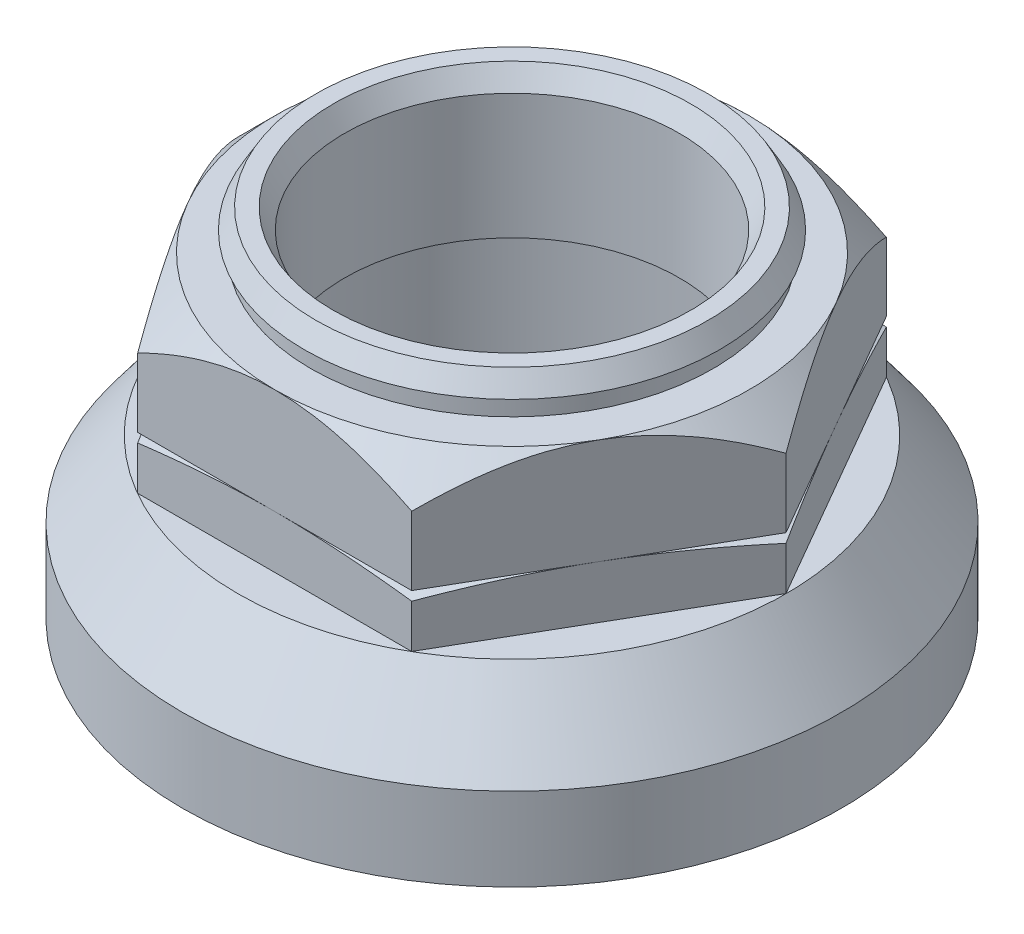
from build123d import *

# Parameters (mm, degrees)
SKETCH2_R      = 17
EXTRUDE1_DEPTH = 4
SKETCH5_R      = 12.7
EXTRUDE2_DEPTH = 8
SKETCH7_R      = 15.25
SKETCH7_R_2    = 12.7
EXTRUDE3_DEPTH = 1.5
SKETCH8_R      = 15.75
SKETCH8_R_2    = 12.7
EXTRUDE4_DEPTH = 1.5
EXTRUDE4_DRAFT = 30


with BuildPart() as part:
    # Sketch1 → Revolve1 (revolve)
    with BuildSketch(Plane(origin=(0, 0, 0), x_dir=(0, 0, -1), z_dir=(1, 0, 0))):
        Polygon((17, 2), (25, 2), (25, 8.3), (20.8, 14), (17, 14), align=None)
    revolve(axis=Axis((0, 2, 0), (0, 1, 0)))

    # Sketch2 → Extrude1 (add)
    with BuildSketch(Plane(origin=(0, 14, 0), x_dir=(1, 0, 0), z_dir=(0, 1, 0))):
        Polygon((10.392304845, 18), (-10.392304845, 18), (-20.784609691, 0), (-10.392304845, -18), (10.392304845, -18), (20.784609691, 0), align=None)
        with Locations(Location((0, 0, 0), (0, 0, 90))):  # turned: the seam where the file's is
            Circle(SKETCH2_R, mode=Mode.SUBTRACT)
    extrude(amount=EXTRUDE1_DEPTH)

    # SurfaceCut1: cut with a surface, the side it looks to stays
    # Surface-Revolve1: a surface, the sketch's curves turned about an axis
    with BuildLine(Plane(origin=(0, 0, 0), x_dir=(0, 0, -1), z_dir=(1, 0, 0)), mode=Mode.PRIVATE) as surface_revolve1_1_path:
        Line((18, 18), (24, 16.5))
    surface_revolve1_1 = Shell.revolve(surface_revolve1_1_path.wire(), 360, Axis((0, 0, 0), (0, 1, 0)))
    split(bisect_by=surface_revolve1_1, keep=Keep.TOP)

    # Sketch9 → Revolve2 (revolve)
    with BuildSketch(Plane(origin=(0, 0, 0), x_dir=(0, 0, -1), z_dir=(1, 0, 0)), mode=Mode.PRIVATE) as revolve2_sk:
        with BuildLine():
            Line((19, 0), (17, 0))
            Line((17, 0), (17, 2))
            Line((17, 2), (22, 2))
            ThreePointArc((22, 2), (20.802775638, 0.545836543), (19, 0))
        make_face()
    revolve(revolve2_sk.sketch.rotate(Axis((0, 0, 0), (0, -1, 0)), 180), axis=Axis((0, 0, 0), (0, -1, 0)))  # turned: the seam where the file's is


with BuildPart() as body_2:
    # Sketch5 → Extrude2 (new body)
    with BuildSketch(Plane(origin=(0, 18, 0), x_dir=(1, 0, 0), z_dir=(0, 1, 0))):
        Polygon((-20.784609691, 0), (-10.392304845, -18), (10.392304845, -18), (20.784609691, 0), (10.392304845, 18), (-10.392304845, 18), align=None)
        with Locations(Location((0, 0, 0), (0, 0, 270))):  # turned: the seam where the file's is
            Circle(SKETCH5_R, mode=Mode.SUBTRACT)
    extrude(amount=EXTRUDE2_DEPTH)

    # SurfaceCut2: cut with a surface, the side behind it stays
    # Surface-Revolve2: a surface, the sketch's curves turned about an axis
    with BuildLine(Plane(origin=(0, 0, 0), x_dir=(0, 0, -1), z_dir=(1, 0, 0)), mode=Mode.PRIVATE) as surface_revolve2_2_path:
        Line((17, 16), (21, 16.5))
        Line((21, 16.5), (21, 23))
        Line((21, 23), (18, 26))
    surface_revolve2_2 = Shell.revolve(surface_revolve2_2_path.wire(), 360, Axis((0, 0, 0), (0, 1, 0)))
    split(bisect_by=surface_revolve2_2, keep=Keep.BOTTOM)

    # Sketch7 → Extrude3 (add)
    with BuildSketch(Plane(origin=(0, 26, 0), x_dir=(1, 0, 0), z_dir=(0, 1, 0))):
        with Locations(Location((0, 0, 0), (0, 0, 270))):  # turned: the seam where the file's is
            Circle(SKETCH7_R)
        with Locations(Location((0, 0, 0), (0, 0, 270))):  # turned: the seam where the file's is
            Circle(SKETCH7_R_2, mode=Mode.SUBTRACT)
    extrude(amount=EXTRUDE3_DEPTH)


with BuildPart() as extrude4_tool:
    # Sketch8 → Extrude4 (with draft: the straight prism first)
    with BuildSketch(Plane(origin=(0, 27.5, 0), x_dir=(1, 0, 0), z_dir=(0, 1, 0))):
        Circle(SKETCH8_R)
        with Locations(Location((0, 0, 0), (0, 0, 270))):  # turned: the seam where the file's is
            Circle(SKETCH8_R_2, mode=Mode.SUBTRACT)
    extrude(amount=EXTRUDE4_DEPTH)
    # Extrude4: the draft: its side faces are tilted about the plane it starts from
    extrude4_sides = [extrude4_tool.faces().sort_by_distance(p)[0] for p in [
        (-15.75, 28.25, 0),
        (0, 28.25, -12.7),
    ]]
    draft(extrude4_sides, Plane(origin=(0, 27.5, 0), x_dir=(1, 0, 0), z_dir=(0, 1, 0)), EXTRUDE4_DRAFT)


with BuildPart() as body_2_1:
    add(body_2.part)

    # Extrude4: add extrude4_tool
    add(extrude4_tool.part)


solid = Compound([part.part, body_2_1.part])
